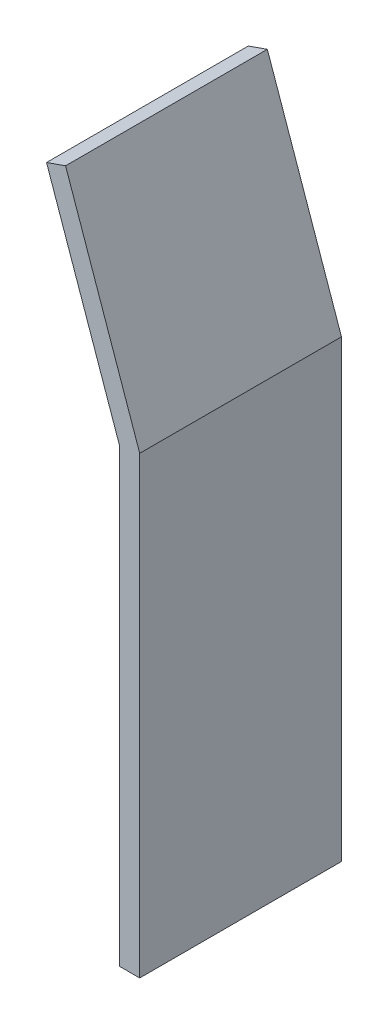
from build123d import *

# Parameters (mm, degrees)
BOSS_EXTRUDE1_DEPTH = 200


with BuildPart() as part:
    # Sketch1 → Boss-Extrude1 (new body)
    with BuildSketch(Plane.XY):
        Polygon((0, 0), (0, -447), (20, -447), (20, 3.397110563), (-53.485002614, 213.472387194), (-72.363327922, 206.868688718), align=None)
    extrude(amount=BOSS_EXTRUDE1_DEPTH)


solid = part.part
